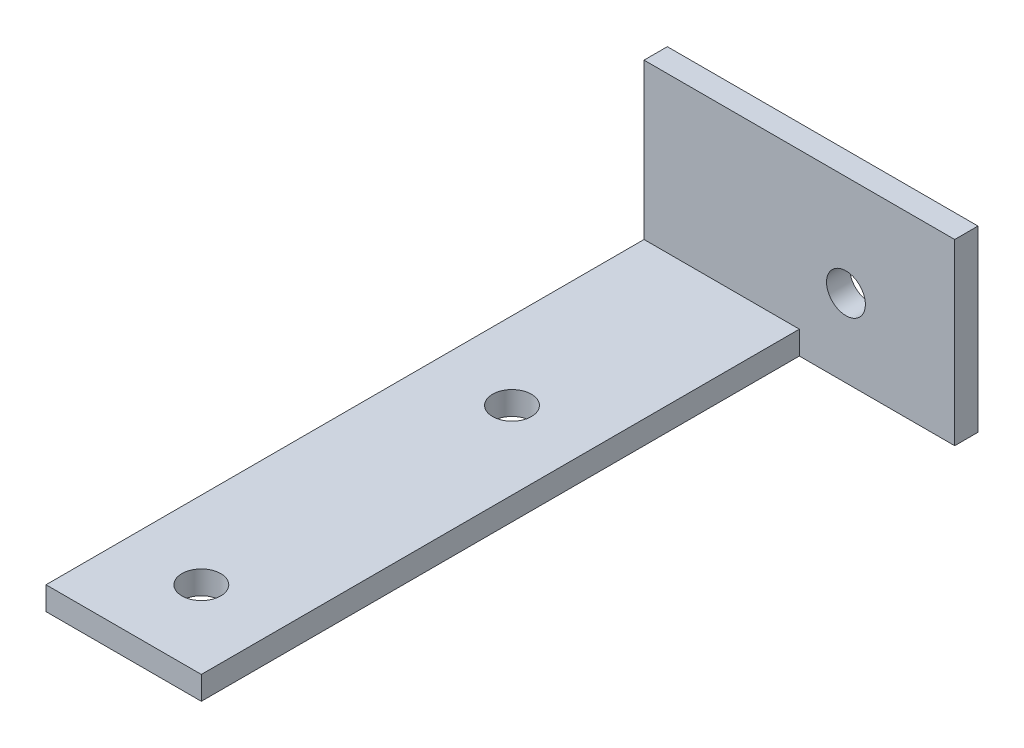
from build123d import *

# Parameters (mm, degrees)
SKETCH1_W           = 20
SKETCH1_H           = 80
SKETCH1_R           = 2.5
BOSS_EXTRUDE1_DEPTH = 3
SKETCH2_W           = 20
SKETCH2_H           = 3
BOSS_EXTRUDE2_DEPTH = 20
SKETCH8_W           = 3
SKETCH8_H           = 23
BOSS_EXTRUDE5_DEPTH = 20
SKETCH9_R           = 2.5
CUT_EXTRUDE3_DEPTH  = 20


with BuildPart() as part:
    # Sketch1 → Boss-Extrude1 (new body)
    with BuildSketch(Plane(origin=(0, 0, 0), x_dir=(1, 0, 0), z_dir=(0, 1, 0))):
        Rectangle(SKETCH1_W, SKETCH1_H)
        with Locations((0, -30)):
            Circle(SKETCH1_R, mode=Mode.SUBTRACT)
        with Locations((0, 10)):
            Circle(SKETCH1_R, mode=Mode.SUBTRACT)
    extrude(amount=BOSS_EXTRUDE1_DEPTH)

    # Sketch2 → Boss-Extrude2 (add)
    with BuildSketch(Plane(origin=(0, 3, 0), x_dir=(1, 0, 0), z_dir=(0, 1, 0))):
        with Locations((0, 38.5)):
            Rectangle(SKETCH2_W, SKETCH2_H)
    extrude(amount=BOSS_EXTRUDE2_DEPTH)

    # Sketch8 → Boss-Extrude5 (add)
    with BuildSketch(Plane(origin=(10, 0, 0), x_dir=(0, 0, -1), z_dir=(1, 0, 0))):
        with Locations((38.5, 11.5)):
            Rectangle(SKETCH8_W, SKETCH8_H)
    extrude(amount=BOSS_EXTRUDE5_DEPTH)

    # Sketch9 → Cut-Extrude3 (cut)
    with BuildSketch(Plane(origin=(0, 0, -40), x_dir=(-1, 0, 0), z_dir=(0, 0, -1))):
        with Locations((-16, 10)):
            Circle(SKETCH9_R)
    extrude(amount=-CUT_EXTRUDE3_DEPTH, mode=Mode.SUBTRACT)


solid = part.part
